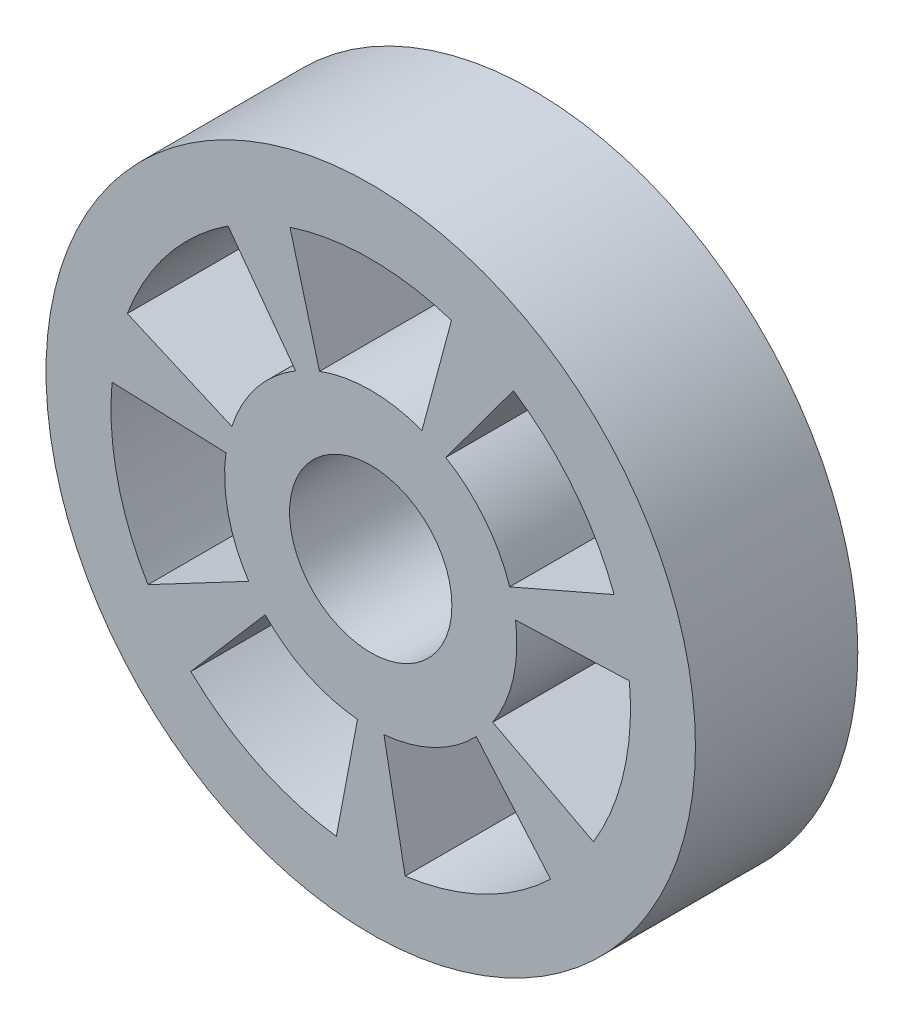
from build123d import *

# Parameters (mm, degrees)
SKETCH1_R           = 50
SKETCH1_R_2         = 12.5
BOSS_EXTRUDE1_DEPTH = 25


with BuildPart() as part:
    # Sketch1 → Boss-Extrude1 (new body)
    with BuildSketch(Plane.XY):
        Circle(SKETCH1_R)
        Circle(SKETCH1_R_2, mode=Mode.SUBTRACT)
        with BuildLine():
            Line((7.8897322, 21.071357949), (12.430935999, 38.019361254))
            ThreePointArc((12.430935999, 38.019361254), (0, 40), (-12.430935999, 38.019361254))
            Line((-12.430935999, 38.019361254), (-7.8897322, 21.071357949))
            ThreePointArc((-7.8897322, 21.071357949), (0, 22.5), (7.8897322, 21.071357949))
        make_face(mode=Mode.SUBTRACT)
        with BuildLine():
            Line((21.393418589, 6.96933577), (37.475295395, 13.985786895))
            ThreePointArc((37.475295395, 13.985786895), (31.273259299, 24.939592074), (21.974171749, 33.423581136))
            Line((21.974171749, 33.423581136), (11.555083457, 19.306217815))
            ThreePointArc((11.555083457, 19.306217815), (17.591208356, 14.028520542), (21.393418589, 6.96933577))
        make_face(mode=Mode.SUBTRACT)
        with BuildLine():
            Line((18.787424434, -12.380738392), (34.299993002, -20.579370255))
            ThreePointArc((34.299993002, -20.579370255), (38.997116487, -8.900837358), (39.832279979, 3.659162705))
            Line((39.832279979, 3.659162705), (22.29868559, 3.003101891))
            ThreePointArc((22.29868559, 3.003101891), (21.935878024, -5.006721014), (18.787424434, -12.380738392))
        make_face(mode=Mode.SUBTRACT)
        with BuildLine():
            Line((2.034116487, -22.407864024), (5.296096286, -39.64784186))
            ThreePointArc((5.296096286, -39.64784186), (17.355349565, -36.038754716), (27.695868954, -28.860679876))
            Line((27.695868954, -28.860679876), (16.250922663, -15.561411009))
            ThreePointArc((16.250922663, -15.561411009), (9.76238413, -20.271799528), (2.034116487, -22.407864024))
        make_face(mode=Mode.SUBTRACT)
        with BuildLine():
            Line((-16.250922663, -15.561411009), (-27.695868954, -28.860679876))
            ThreePointArc((-27.695868954, -28.860679876), (-17.355349565, -36.038754716), (-5.296096286, -39.64784186))
            Line((-5.296096286, -39.64784186), (-2.034116487, -22.407864024))
            ThreePointArc((-2.034116487, -22.407864024), (-9.76238413, -20.271799528), (-16.250922663, -15.561411009))
        make_face(mode=Mode.SUBTRACT)
        with BuildLine():
            Line((-22.29868559, 3.003101891), (-39.832279979, 3.659162705))
            ThreePointArc((-39.832279979, 3.659162705), (-38.997116487, -8.900837358), (-34.299993002, -20.579370255))
            Line((-34.299993002, -20.579370255), (-18.787424434, -12.380738392))
            ThreePointArc((-18.787424434, -12.380738392), (-21.935878024, -5.006721014), (-22.29868559, 3.003101891))
        make_face(mode=Mode.SUBTRACT)
        with BuildLine():
            Line((-11.555083457, 19.306217815), (-21.974171749, 33.423581136))
            ThreePointArc((-21.974171749, 33.423581136), (-31.273259299, 24.939592074), (-37.475295395, 13.985786895))
            Line((-37.475295395, 13.985786895), (-21.393418589, 6.96933577))
            ThreePointArc((-21.393418589, 6.96933577), (-17.591208356, 14.028520542), (-11.555083457, 19.306217815))
        make_face(mode=Mode.SUBTRACT)
    extrude(amount=BOSS_EXTRUDE1_DEPTH)


solid = part.part
